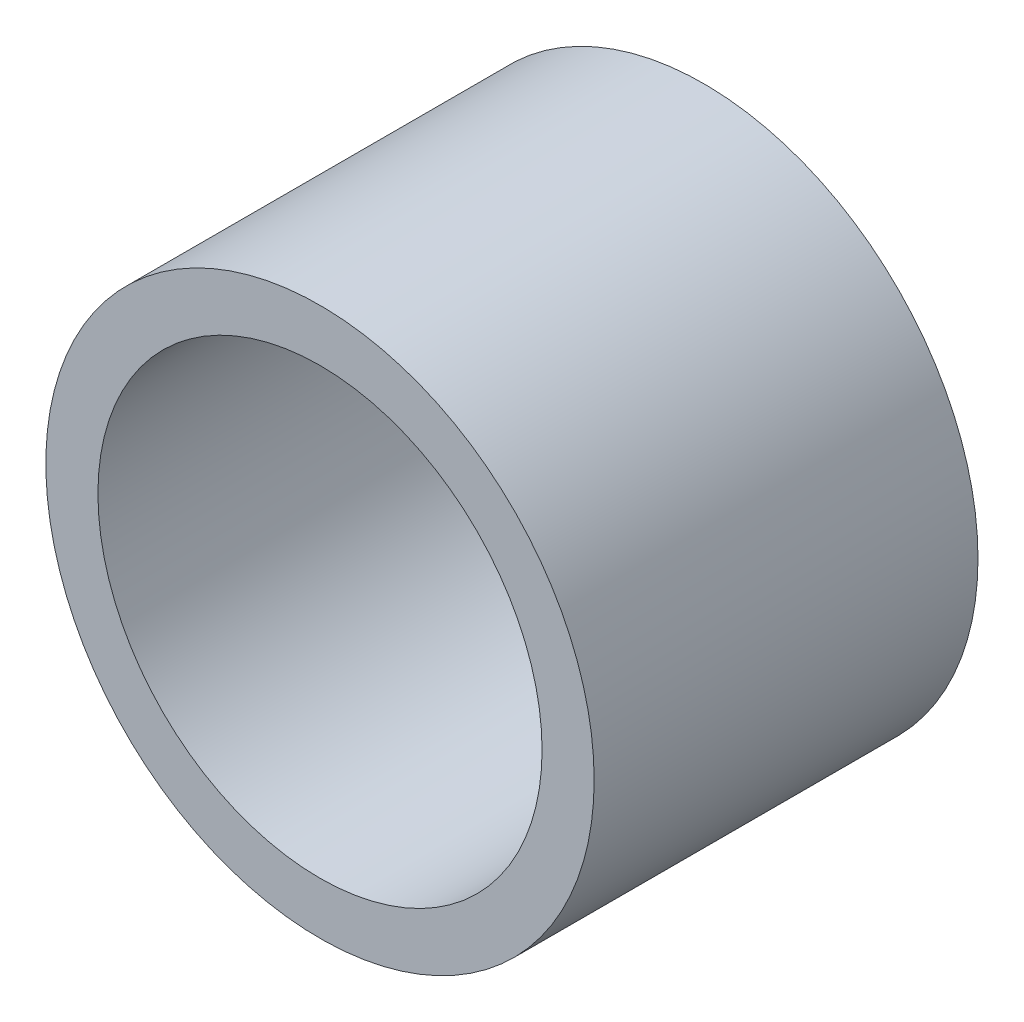
from build123d import *

# Parameters (mm, degrees)
SKETCH1_R           = 5
SKETCH1_R_2         = 4.05
BOSS_EXTRUDE1_DEPTH = 7


with BuildPart() as part:
    # Sketch1 → Boss-Extrude1 (new body)
    with BuildSketch(Plane.XY):
        Circle(SKETCH1_R)
        Circle(SKETCH1_R_2, mode=Mode.SUBTRACT)
    extrude(amount=BOSS_EXTRUDE1_DEPTH)


solid = part.part
